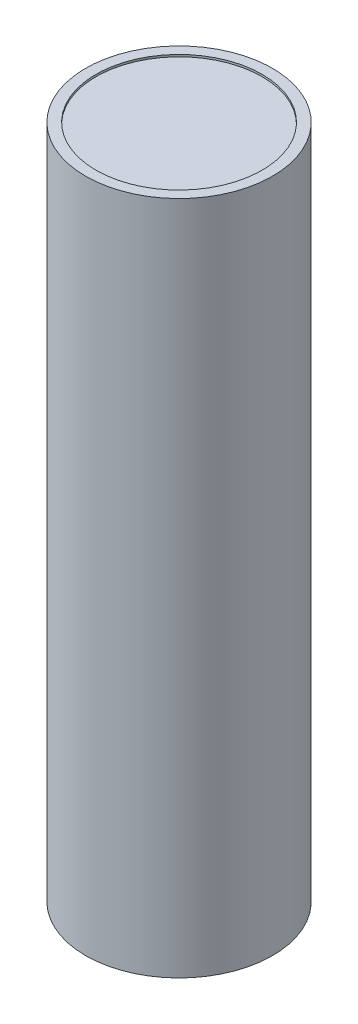
from build123d import *

# Parameters (mm, degrees)
SKETCH1_R           = 9
BOSS_EXTRUDE1_DEPTH = 65
SKETCH2_R           = 8
CUT_EXTRUDE1_DEPTH  = 0.2
SKETCH3_R           = 8
CUT_EXTRUDE2_DEPTH  = 0.2


with BuildPart() as part:
    # Sketch1 → Boss-Extrude1 (new body)
    with BuildSketch(Plane(origin=(0, 0, 0), x_dir=(1, 0, 0), z_dir=(0, 1, 0))):
        Circle(SKETCH1_R)
    extrude(amount=BOSS_EXTRUDE1_DEPTH)

    # Sketch2 → Cut-Extrude1 (cut)
    with BuildSketch(Plane(origin=(0, 65, 0), x_dir=(1, 0, 0), z_dir=(0, 1, 0))):
        Circle(SKETCH2_R)
    extrude(amount=-CUT_EXTRUDE1_DEPTH, mode=Mode.SUBTRACT)

    # Sketch3 → Cut-Extrude2 (cut)
    with BuildSketch(Plane.XZ):
        Circle(SKETCH3_R)
    extrude(amount=-CUT_EXTRUDE2_DEPTH, mode=Mode.SUBTRACT)


solid = part.part
